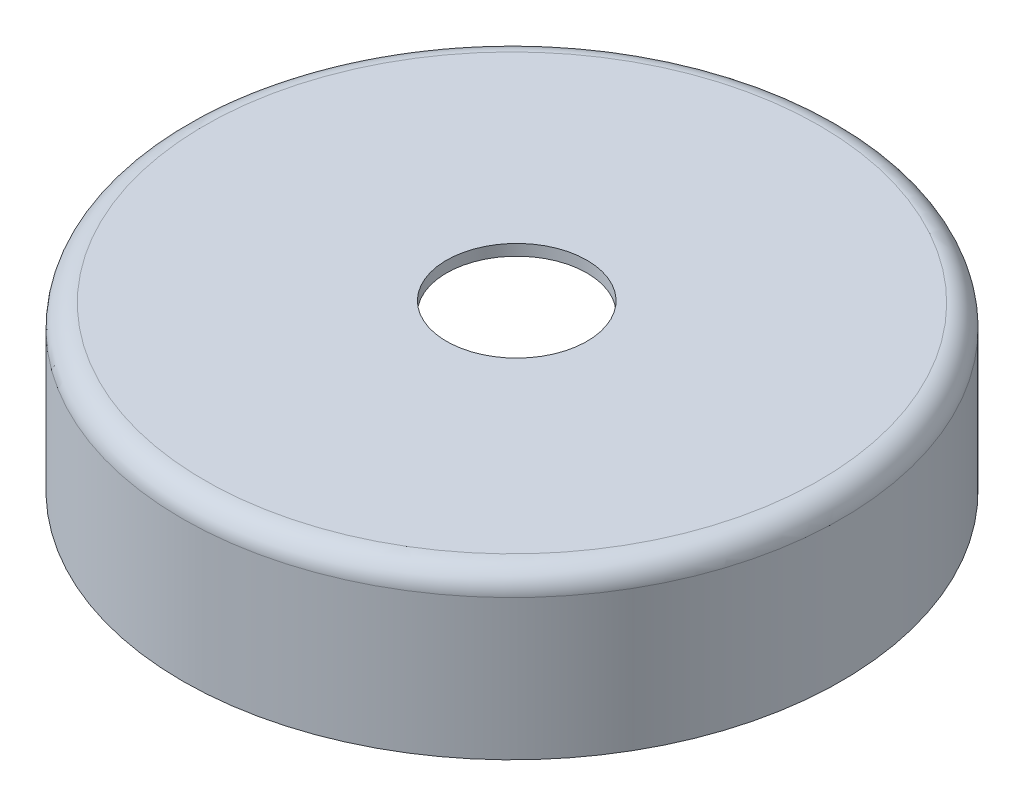
from build123d import *

# Parameters (mm, degrees)
SKETCH1_W               = 141.4859375
SKETCH1_H               = 69.85
FILLET1_R               = 9.525
SHELL1_T                = -4.7625
SKETCH3_R               = 30.1625
CUT_EXTRUDE1_DEPTH      = 30.734
CUT_EXTRUDE1_DEPTH_BACK = 28.194


with BuildPart() as part:
    # Sketch1 → Revolve1 (revolve)
    with BuildSketch(Plane(origin=(0, 0, 0), x_dir=(0, 0, -1), z_dir=(1, 0, 0)), mode=Mode.PRIVATE) as revolve1_sk:
        with Locations((-70.74296875, 34.925)):
            Rectangle(SKETCH1_W, SKETCH1_H)
    revolve(revolve1_sk.sketch.rotate(Axis((0, 0, 0), (0, 1, 0)), 180), axis=Axis((0, 0, 0), (0, 1, 0)))

    # Fillet1
    fillet1_edges = [part.edges().sort_by_distance(p)[0] for p in [
        (0, 69.85, 141.4859375),
    ]]
    fillet(fillet1_edges, radius=FILLET1_R)

    # Shell1
    shell1_openings = [part.faces().sort_by_distance(p)[0] for p in [
        (0, 0, 0),
    ]]
    offset(amount=SHELL1_T, openings=shell1_openings, kind=Kind.INTERSECTION)

    # Sketch3 → Cut-Extrude1 (cut, two sides)
    with BuildSketch(Plane(origin=(0, 69.85, 0), x_dir=(1, 0, 0), z_dir=(0, 1, 0))) as cut_extrude1_sk:
        with Locations(Location((0.218944766, 1.810655032, 0), (0, 0, 90))):
            Circle(SKETCH3_R)
    extrude(amount=CUT_EXTRUDE1_DEPTH, mode=Mode.SUBTRACT)
    extrude(cut_extrude1_sk.sketch, amount=-CUT_EXTRUDE1_DEPTH_BACK, mode=Mode.SUBTRACT)


solid = part.part
